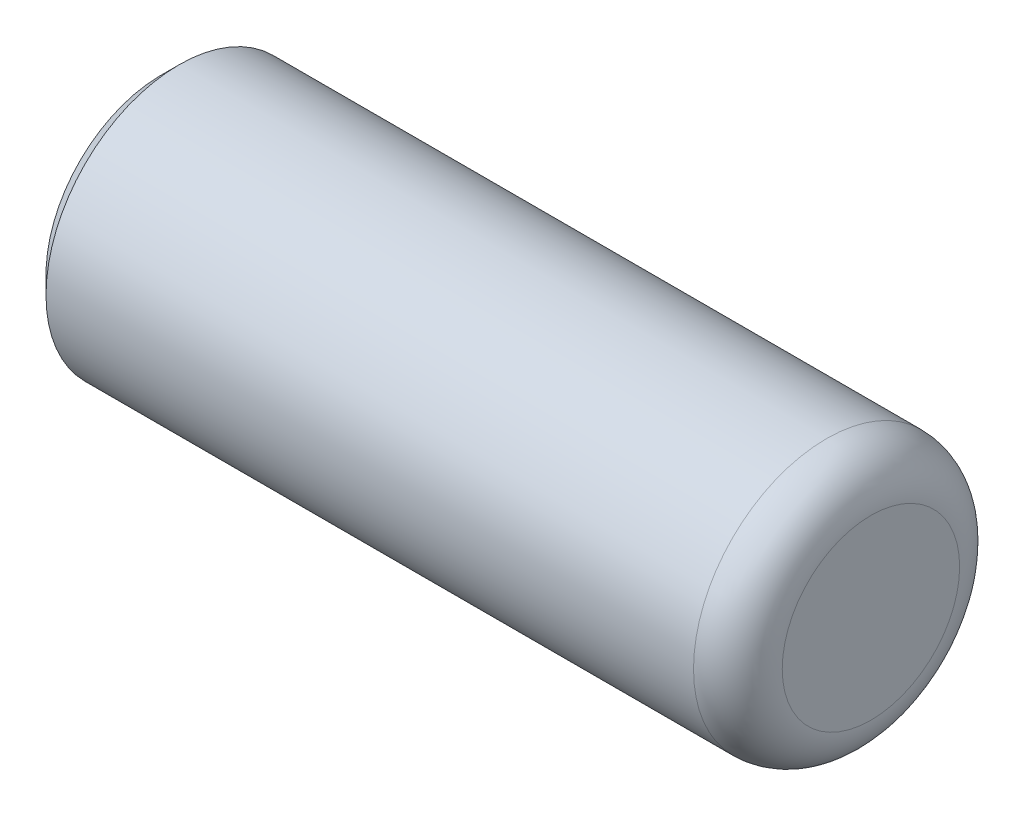
from build123d import *

# Parameters (mm, degrees)
SKETCH1_R           = 1.5
BOSS_EXTRUDE1_DEPTH = 4
FILLET1_R           = 0.5
CHAMFER1_SIZE       = 0.2


with BuildPart() as part:
    # Sketch1 → Boss-Extrude1 (new body, symmetric)
    with BuildSketch(Plane(origin=(0, 0, 0), x_dir=(0, -1, 0), z_dir=(1, 0, 0))):
        Circle(SKETCH1_R)
    extrude(amount=BOSS_EXTRUDE1_DEPTH, both=True)

    # Fillet1
    fillet1_edges = [part.edges().sort_by_distance(p)[0] for p in [
        (4, 1.5, 0),
    ]]
    fillet(fillet1_edges, radius=FILLET1_R)

    # Chamfer1
    chamfer1_edges = [part.edges().sort_by_distance(p)[0] for p in [
        (-4, 1.5, 0),
    ]]
    chamfer(chamfer1_edges, length=CHAMFER1_SIZE)


solid = part.part
